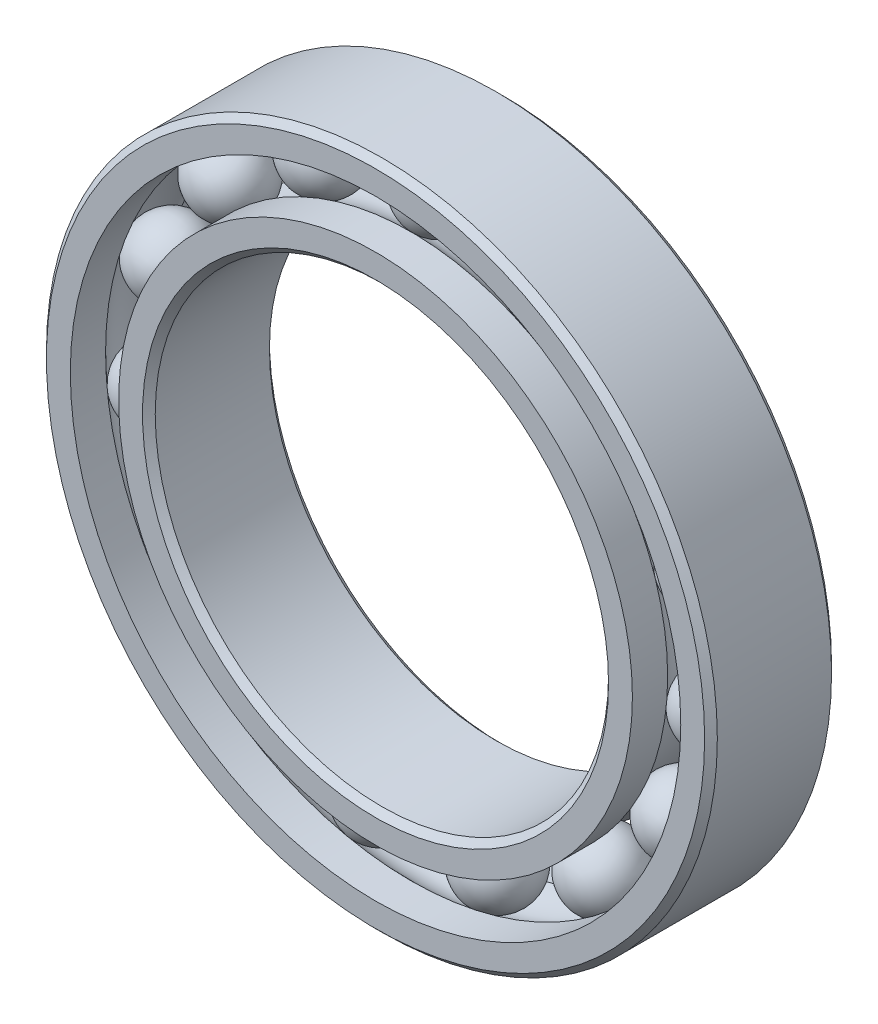
from build123d import *

# Parameters (mm, degrees)
CIRPATTERN1_COUNT = 15


with BuildPart() as part:
    # Sketch5 → Revolve1 (revolve)
    with BuildSketch(Plane(origin=(0, 0, 0), x_dir=(0, 0, -1), z_dir=(1, 0, 0))):
        with BuildLine():
            Line((3.15, 18.5), (-3.15, 18.5))
            Line((-3.15, 18.5), (-3.5, 18.15))
            Line((-3.5, 18.15), (-3.5, 16.833333333))
            Line((-3.5, 16.833333333), (-1.555555556, 16.833333333))
            ThreePointArc((-1.555555556, 16.833333333), (0, 17.548787657), (1.555555556, 16.833333333))
            Line((1.555555556, 16.833333333), (3.5, 16.833333333))
            Line((3.5, 16.833333333), (3.5, 18.15))
            Line((3.5, 18.15), (3.15, 18.5))
        make_face()
    revolve(axis=Axis((0, 0, 3.5), (0, 0, -1)))


with BuildPart() as body_2:
    # Sketch3 → Revolve3 (revolve)
    with BuildSketch(Plane(origin=(0, 0, 0), x_dir=(0, 0, -1), z_dir=(1, 0, 0))):
        with BuildLine():
            Line((-3.5, 14.166666667), (-1.555555556, 14.166666667))
            ThreePointArc((-1.555555556, 14.166666667), (0, 13.451212343), (1.555555556, 14.166666667))
            Line((1.555555556, 14.166666667), (3.5, 14.166666667))
            Line((3.5, 14.166666667), (3.5, 12.85))
            Line((3.5, 12.85), (3.15, 12.5))
            Line((3.15, 12.5), (-3.15, 12.5))
            Line((-3.15, 12.5), (-3.5, 12.85))
            Line((-3.5, 12.85), (-3.5, 14.166666667))
        make_face()
    revolve(axis=Axis((0, 0, 3.5), (0, 0, -1)))


with BuildPart() as body_3:
    # Sketch4 → Revolve4 (revolve)
    with BuildSketch(Plane(origin=(0, 0, 0), x_dir=(0, 0, -1), z_dir=(1, 0, 0))):
        with BuildLine():
            Line((-2.048787657, 15.5), (2.048787657, 15.5))
            ThreePointArc((2.048787657, 15.5), (0, 17.548787657), (-2.048787657, 15.5))
        make_face()
    revolve(axis=Axis((0, 15.5, 2.048787657), (0, 0, -1)))


with BuildPart() as cirpattern1_1:
    # CirPattern1: pattern copy
    add(body_3.part.rotate(Axis((0, 0, 0), (0, 0, 1)), 1 * 360 / CIRPATTERN1_COUNT))


with BuildPart() as cirpattern1_2:
    # CirPattern1: pattern copy
    add(body_3.part.rotate(Axis((0, 0, 0), (0, 0, 1)), 2 * 360 / CIRPATTERN1_COUNT))


with BuildPart() as cirpattern1_3:
    # CirPattern1: pattern copy
    add(body_3.part.rotate(Axis((0, 0, 0), (0, 0, 1)), 3 * 360 / CIRPATTERN1_COUNT))


with BuildPart() as cirpattern1_4:
    # CirPattern1: pattern copy
    add(body_3.part.rotate(Axis((0, 0, 0), (0, 0, 1)), 4 * 360 / CIRPATTERN1_COUNT))


with BuildPart() as cirpattern1_5:
    # CirPattern1: pattern copy
    add(body_3.part.rotate(Axis((0, 0, 0), (0, 0, 1)), 5 * 360 / CIRPATTERN1_COUNT))


with BuildPart() as cirpattern1_6:
    # CirPattern1: pattern copy
    add(body_3.part.rotate(Axis((0, 0, 0), (0, 0, 1)), 6 * 360 / CIRPATTERN1_COUNT))


with BuildPart() as cirpattern1_7:
    # CirPattern1: pattern copy
    add(body_3.part.rotate(Axis((0, 0, 0), (0, 0, 1)), 7 * 360 / CIRPATTERN1_COUNT))


with BuildPart() as cirpattern1_8:
    # CirPattern1: pattern copy
    add(body_3.part.rotate(Axis((0, 0, 0), (0, 0, 1)), 8 * 360 / CIRPATTERN1_COUNT))


with BuildPart() as cirpattern1_9:
    # CirPattern1: pattern copy
    add(body_3.part.rotate(Axis((0, 0, 0), (0, 0, 1)), 9 * 360 / CIRPATTERN1_COUNT))


with BuildPart() as cirpattern1_10:
    # CirPattern1: pattern copy
    add(body_3.part.rotate(Axis((0, 0, 0), (0, 0, 1)), 10 * 360 / CIRPATTERN1_COUNT))


with BuildPart() as cirpattern1_11:
    # CirPattern1: pattern copy
    add(body_3.part.rotate(Axis((0, 0, 0), (0, 0, 1)), 11 * 360 / CIRPATTERN1_COUNT))


with BuildPart() as cirpattern1_12:
    # CirPattern1: pattern copy
    add(body_3.part.rotate(Axis((0, 0, 0), (0, 0, 1)), 12 * 360 / CIRPATTERN1_COUNT))


with BuildPart() as cirpattern1_13:
    # CirPattern1: pattern copy
    add(body_3.part.rotate(Axis((0, 0, 0), (0, 0, 1)), 13 * 360 / CIRPATTERN1_COUNT))


with BuildPart() as cirpattern1_14:
    # CirPattern1: pattern copy
    add(body_3.part.rotate(Axis((0, 0, 0), (0, 0, 1)), 14 * 360 / CIRPATTERN1_COUNT))


solid = Compound([part.part, body_2.part, body_3.part, cirpattern1_1.part, cirpattern1_2.part, cirpattern1_3.part, cirpattern1_4.part, cirpattern1_5.part, cirpattern1_6.part, cirpattern1_7.part, cirpattern1_8.part, cirpattern1_9.part, cirpattern1_10.part, cirpattern1_11.part, cirpattern1_12.part, cirpattern1_13.part, cirpattern1_14.part])
